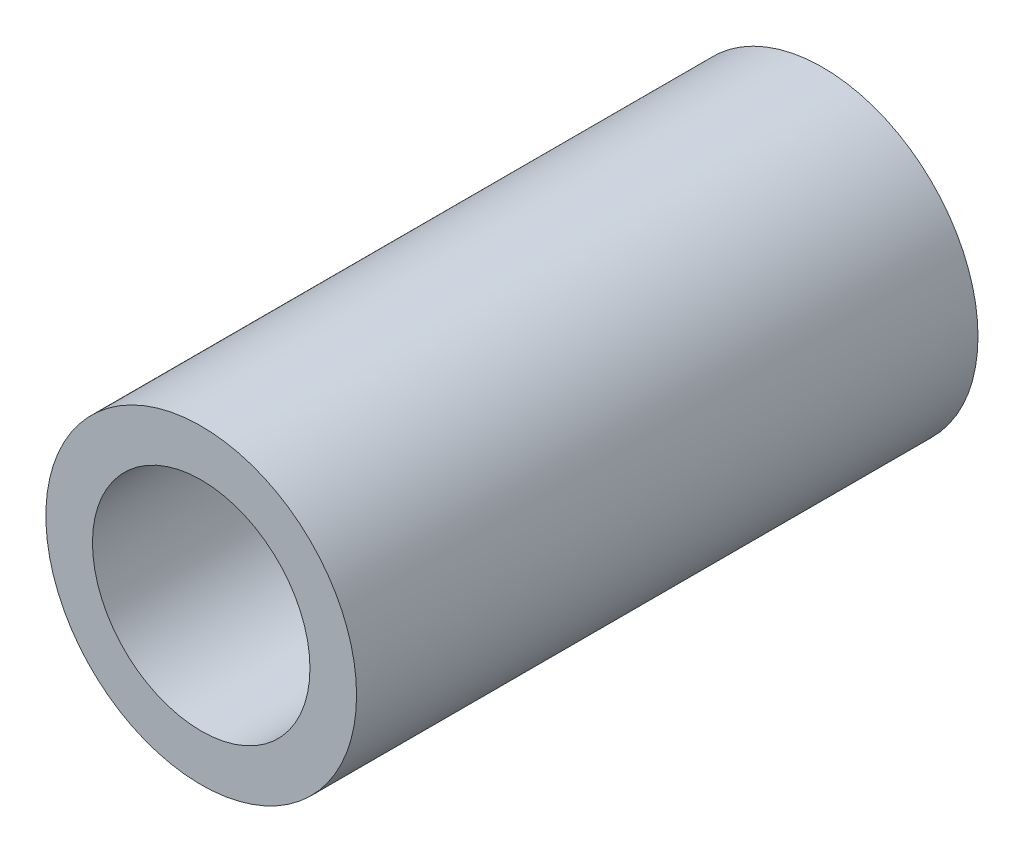
from build123d import *

# Parameters (mm, degrees)
SKETCH1_R           = 2.5
BOSS_EXTRUDE1_DEPTH = 10
SKETCH2_R           = 1.75
CUT_EXTRUDE1_DEPTH  = 10


with BuildPart() as part:
    # Sketch1 → Boss-Extrude1 (new body)
    with BuildSketch(Plane.XY):
        Circle(SKETCH1_R)
    extrude(amount=BOSS_EXTRUDE1_DEPTH)

    # Sketch2 → Cut-Extrude1 (cut)
    with BuildSketch(Plane.XY.offset(10)):
        Circle(SKETCH2_R)
    extrude(amount=-CUT_EXTRUDE1_DEPTH, mode=Mode.SUBTRACT)


solid = part.part
